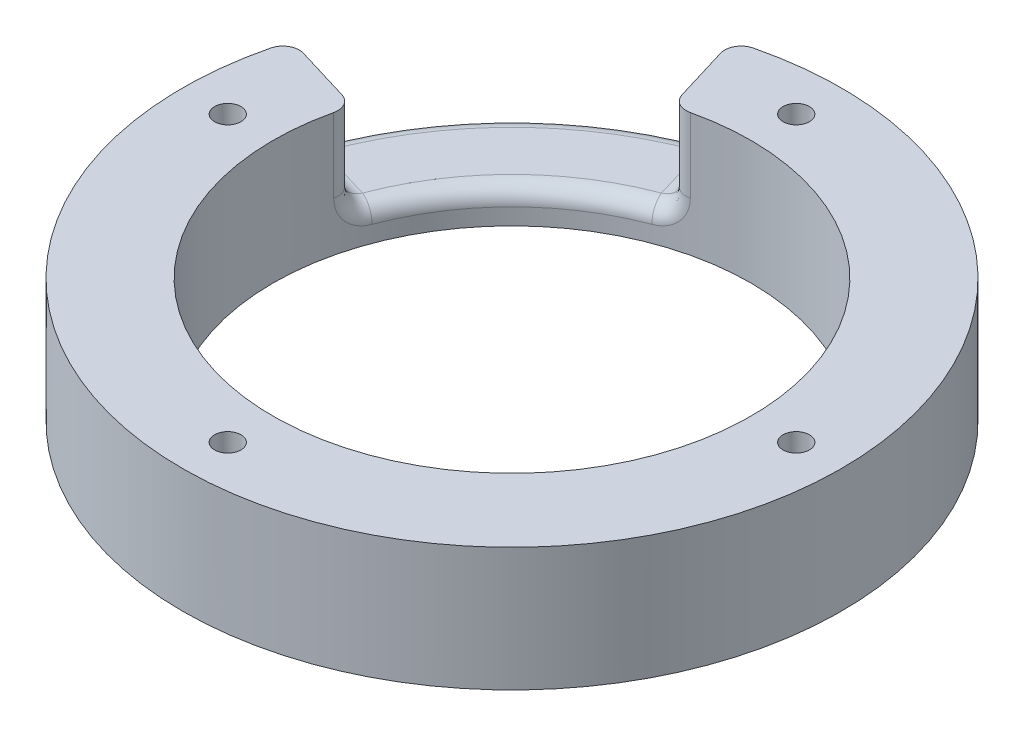
from build123d import *

# Parameters (mm, degrees)
SKETCH_1_R          = 40
SKETCH_1_R_2        = 29
SKETCH_1_R_3        = 1.6
EXTRUDE_1_DEPTH     = 15
CUT_EXTRUDE_1_DEPTH = 11
FILLET_1_R          = 2


with BuildPart() as part:
    # 草图1 → 凸台-拉伸1 (new body)
    with BuildSketch(Plane(origin=(0, 0, 0), x_dir=(1, 0, 0), z_dir=(0, 1, 0))):
        Circle(SKETCH_1_R)
        Circle(SKETCH_1_R_2, mode=Mode.SUBTRACT)
        with Locations((0, 34.5)):
            Circle(SKETCH_1_R_3, mode=Mode.SUBTRACT)
        with Locations((34.5, 0)):
            Circle(SKETCH_1_R_3, mode=Mode.SUBTRACT)
        with Locations((-34.5, 0)):
            Circle(SKETCH_1_R_3, mode=Mode.SUBTRACT)
        with Locations((0, -34.5)):
            Circle(SKETCH_1_R_3, mode=Mode.SUBTRACT)
    extrude(amount=EXTRUDE_1_DEPTH)

    # 草图2 → 切除-拉伸1 (cut)
    with BuildSketch(Plane(origin=(0, 15, 0), x_dir=(1, 0, 0), z_dir=(0, 1, 0))):
        with BuildLine():
            Line((-8.405801697, 27.755044548), (-11.594209237, 38.282820066))
            ThreePointArc((-11.594209237, 38.282820066), (-28.284271247, 28.284271247), (-38.282820066, 11.594209237))
            Line((-38.282820066, 11.594209237), (-27.755044548, 8.405801697))
            ThreePointArc((-27.755044548, 8.405801697), (-20.506096654, 20.506096654), (-8.405801697, 27.755044548))
        make_face()
    extrude(amount=-CUT_EXTRUDE_1_DEPTH, mode=Mode.SUBTRACT)

    # 圆角1
    fillet_1_edges = [part.edges().sort_by_distance(p)[0] for p in [
        (-28.284271247, 4, -28.284271247),
        (-38.282820066, 9.5, -11.594209237),
        (-11.594209237, 9.5, -38.282820066),
        (-20.506096654, 4, -20.506096654),
        (-8.405801697, 9.5, -27.755044548),
        (-33.018932307, 4, -10.000005467),
        (-27.755044548, 9.5, -8.405801697),
        (-10.000005467, 4, -33.018932307),
    ]]
    fillet(fillet_1_edges, radius=FILLET_1_R)


solid = part.part
